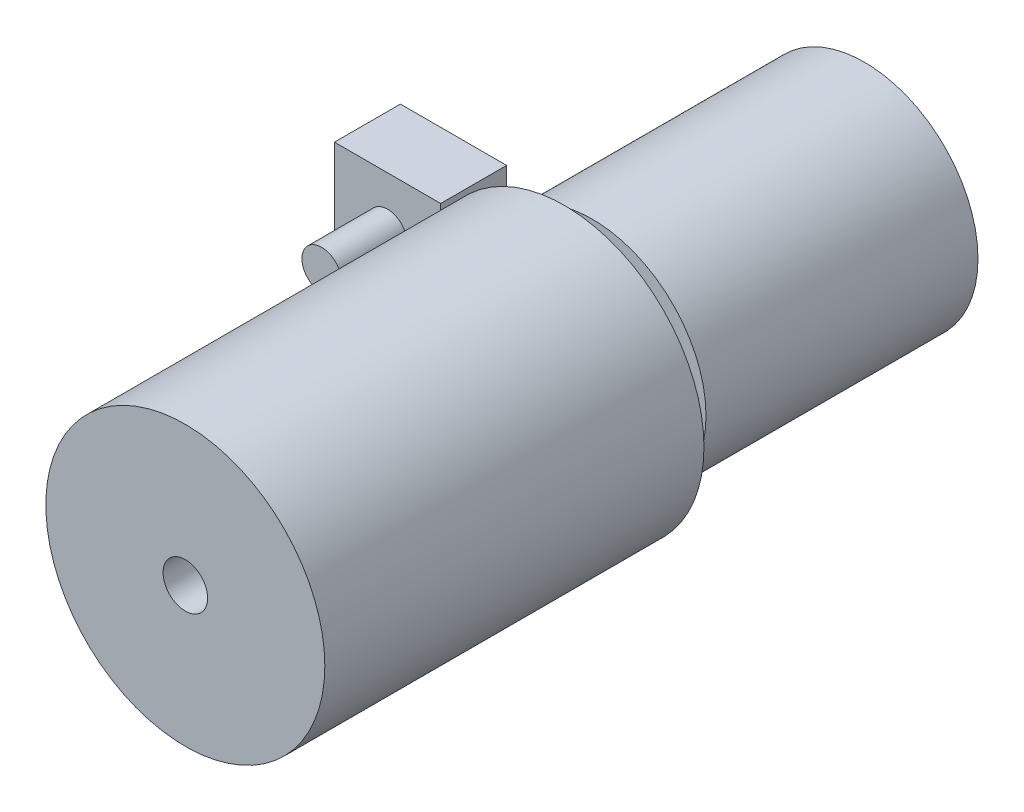
from build123d import *

# Parameters (mm, degrees)
SKETCH2_R           = 13.771311666
BOSS_EXTRUDE1_DEPTH = 33
SKETCH4_R           = 2.670460619
BOSS_EXTRUDE2_DEPTH = 3.401159468
SKETCH5_R           = 2.391755936
BOSS_EXTRUDE3_DEPTH = 8
SKETCH6_W           = 12.884717539
SKETCH6_H           = 12.427625198
BOSS_EXTRUDE4_DEPTH = 8
SKETCH24_R          = 16.92460457
SKETCH24_R_2        = 2.7046062
BOSS_EXTRUDE9_DEPTH = 46


with BuildPart() as part:
    # Sketch2 → Boss-Extrude1 (new body)
    with BuildSketch(Plane.XY):
        Circle(SKETCH2_R)
    extrude(amount=BOSS_EXTRUDE1_DEPTH)

    # Sketch4 → Boss-Extrude2 (add)
    with BuildSketch(Plane.XY.offset(33)):
        Circle(SKETCH4_R)
    extrude(amount=BOSS_EXTRUDE2_DEPTH)


with BuildPart() as body_2:
    # Sketch5 → Boss-Extrude3 (new body)
    with BuildSketch(Plane.XY.offset(33)):
        with Locations((-24.864724485, 0)):
            Circle(SKETCH5_R)
    extrude(amount=BOSS_EXTRUDE3_DEPTH)

    # Sketch6 → Boss-Extrude4 (add)
    with BuildSketch(Plane(origin=(0, 0, 33), x_dir=(-1, 0, 0), z_dir=(0, 0, -1))):
        with Locations((24.864724486, 0)):
            Rectangle(SKETCH6_W, SKETCH6_H)
    extrude(amount=BOSS_EXTRUDE4_DEPTH)


with BuildPart() as body_3:
    # Sketch24 → Boss-Extrude9 (new body)
    with BuildSketch(Plane.XY.offset(36.401159468)):
        Circle(SKETCH24_R)
        Circle(SKETCH24_R_2, mode=Mode.SUBTRACT)
    extrude(amount=BOSS_EXTRUDE9_DEPTH)


solid = Compound([part.part, body_2.part, body_3.part])
